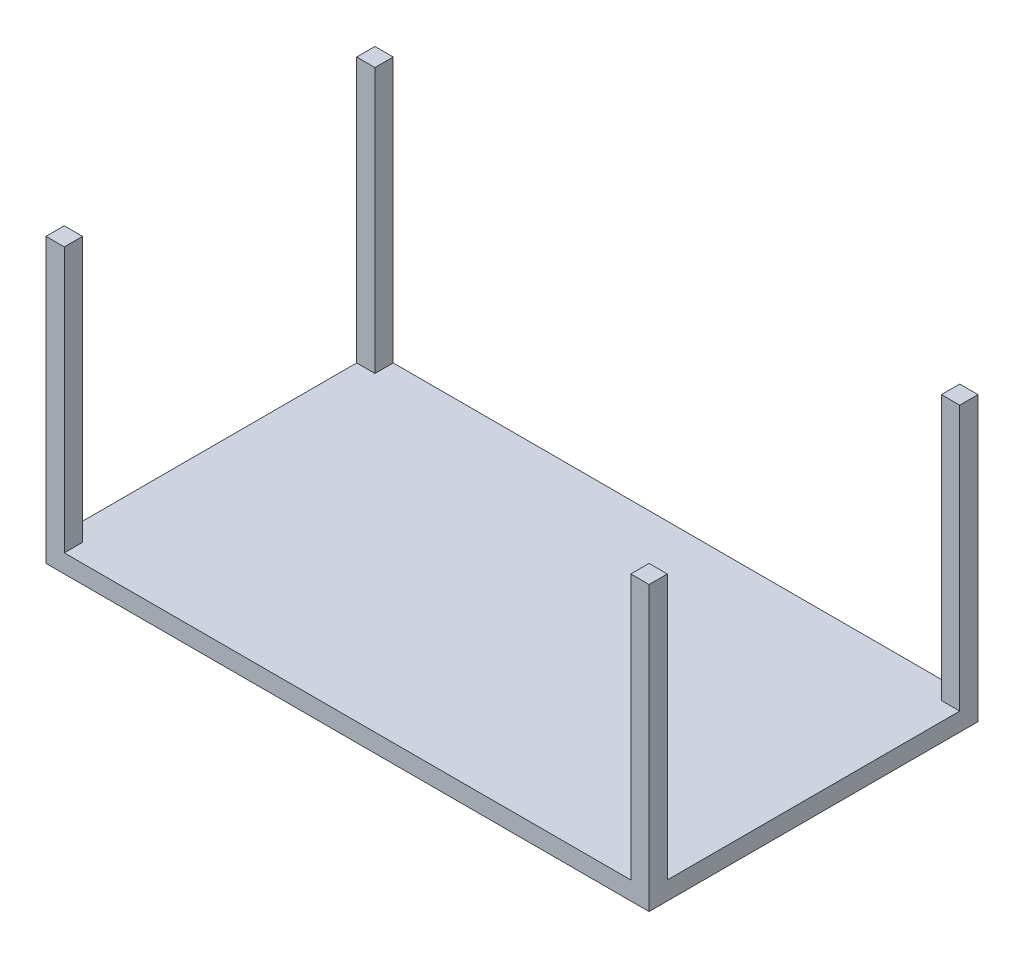
from build123d import *

# Parameters (mm, degrees)
SKETCH1_W           = 1676.4
SKETCH1_H           = 914.4
BOSS_EXTRUDE1_DEPTH = 50.8
SKETCH2_W           = 50.8
SKETCH2_H           = 50.8
BOSS_EXTRUDE2_DEPTH = 736.6


with BuildPart() as part:
    # Sketch1 → Boss-Extrude1 (new body)
    with BuildSketch(Plane(origin=(0, 0, 0), x_dir=(1, 0, 0), z_dir=(0, 1, 0))):
        Rectangle(SKETCH1_W, SKETCH1_H)
    extrude(amount=BOSS_EXTRUDE1_DEPTH)

    # Sketch2 → Boss-Extrude2 (add)
    with BuildSketch(Plane(origin=(0, 50.8, 0), x_dir=(1, 0, 0), z_dir=(0, 1, 0))):
        with Locations((-812.8, 431.8)):
            Rectangle(SKETCH2_W, SKETCH2_H)
        with Locations((812.8, 431.8)):
            Rectangle(SKETCH2_W, SKETCH2_H)
        with Locations((812.8, -431.8)):
            Rectangle(SKETCH2_W, SKETCH2_H)
        with Locations((-812.8, -431.8)):
            Rectangle(SKETCH2_W, SKETCH2_H)
    extrude(amount=BOSS_EXTRUDE2_DEPTH)


solid = part.part
